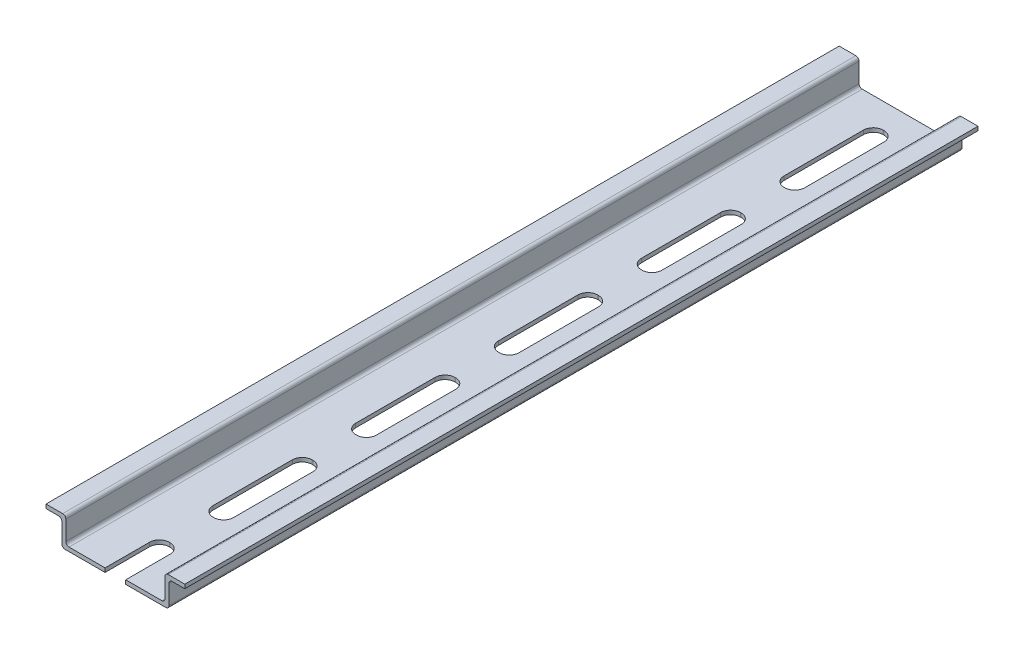
from build123d import *

# Parameters (mm, degrees)
BOSS_EXTRUDE1_DEPTH = 200
CUT_EXTRUDE1_DEPTH  = 2


with BuildPart() as part:
    # Sketch1 → Boss-Extrude1 (new body)
    with BuildSketch(Plane.XY):
        with BuildLine():
            Line((0, 0), (0, 1))
            Line((0, 1), (4.2, 1))
            ThreePointArc((4.2, 1), (4.765685425, 0.765685425), (5, 0.2))
            Line((5, 0.2), (5, -4.7))
            ThreePointArc((5, -4.7), (5.234314575, -5.265685425), (5.8, -5.5))
            Line((5.8, -5.5), (29.2, -5.5))
            ThreePointArc((29.2, -5.5), (29.765685425, -5.265685425), (30, -4.7))
            Line((30, -4.7), (30, 0.2))
            ThreePointArc((30, 0.2), (30.234314575, 0.765685425), (30.8, 1))
            Line((30.8, 1), (35, 1))
            Line((35, 1), (35, 0))
            Line((35, 0), (31.8, 0))
            ThreePointArc((31.8, 0), (31.234314575, -0.234314575), (31, -0.8))
            Line((31, -0.8), (31, -5.7))
            ThreePointArc((31, -5.7), (30.765685425, -6.265685425), (30.2, -6.5))
            Line((30.2, -6.5), (4.8, -6.5))
            ThreePointArc((4.8, -6.5), (4.234314575, -6.265685425), (4, -5.7))
            Line((4, -5.7), (4, -0.8))
            ThreePointArc((4, -0.8), (3.765685425, -0.234314575), (3.2, 0))
            Line((3.2, 0), (0, 0))
        make_face()
    extrude(amount=BOSS_EXTRUDE1_DEPTH)

    # Sketch2 → Cut-Extrude1 (cut, through all)
    with BuildSketch(Plane(origin=(0, -5.5, 0), x_dir=(1, 0, 0), z_dir=(0, 1, 0))):
        with BuildLine():
            Line((17.4, -6.300946702), (17.6, -6.300946702))
            ThreePointArc((17.6, -6.300946702), (19.367766953, -7.033179749), (20.1, -8.800946702))
            Line((20.1, -8.800946702), (20.1, -28.800946702))
            ThreePointArc((20.1, -28.800946702), (19.367766953, -30.568713655), (17.6, -31.300946702))
            Line((17.6, -31.300946702), (17.4, -31.300946702))
            ThreePointArc((17.4, -31.300946702), (15.632233047, -30.568713655), (14.9, -28.800946702))
            Line((14.9, -28.800946702), (14.9, -8.800946702))
            ThreePointArc((14.9, -8.800946702), (15.632233047, -7.033179749), (17.4, -6.300946702))
        make_face()
        with BuildLine():
            Line((14.9, -44.800946702), (14.9, -64.800946702))
            ThreePointArc((14.9, -64.800946702), (15.632233047, -66.568713655), (17.4, -67.300946702))
            Line((17.4, -67.300946702), (17.6, -67.300946702))
            ThreePointArc((17.6, -67.300946702), (19.367766953, -66.568713655), (20.1, -64.800946702))
            Line((20.1, -64.800946702), (20.1, -44.800946702))
            ThreePointArc((20.1, -44.800946702), (19.367766953, -43.033179749), (17.6, -42.300946702))
            Line((17.6, -42.300946702), (17.4, -42.300946702))
            ThreePointArc((17.4, -42.300946702), (15.632233047, -43.033179749), (14.9, -44.800946702))
        make_face()
        with BuildLine():
            Line((14.9, -80.800946702), (14.9, -100.800946702))
            ThreePointArc((14.9, -100.800946702), (15.632233047, -102.568713655), (17.4, -103.300946702))
            Line((17.4, -103.300946702), (17.6, -103.300946702))
            ThreePointArc((17.6, -103.300946702), (19.367766953, -102.568713655), (20.1, -100.800946702))
            Line((20.1, -100.800946702), (20.1, -80.800946702))
            ThreePointArc((20.1, -80.800946702), (19.367766953, -79.033179749), (17.6, -78.300946702))
            Line((17.6, -78.300946702), (17.4, -78.300946702))
            ThreePointArc((17.4, -78.300946702), (15.632233047, -79.033179749), (14.9, -80.800946702))
        make_face()
        with BuildLine():
            Line((14.9, -116.800946702), (14.9, -136.800946702))
            ThreePointArc((14.9, -136.800946702), (15.632233047, -138.568713655), (17.4, -139.300946702))
            Line((17.4, -139.300946702), (17.6, -139.300946702))
            ThreePointArc((17.6, -139.300946702), (19.367766953, -138.568713655), (20.1, -136.800946702))
            Line((20.1, -136.800946702), (20.1, -116.800946702))
            ThreePointArc((20.1, -116.800946702), (19.367766953, -115.033179749), (17.6, -114.300946702))
            Line((17.6, -114.300946702), (17.4, -114.300946702))
            ThreePointArc((17.4, -114.300946702), (15.632233047, -115.033179749), (14.9, -116.800946702))
        make_face()
        with BuildLine():
            Line((14.9, -152.800946702), (14.9, -172.800946702))
            ThreePointArc((14.9, -172.800946702), (15.632233047, -174.568713655), (17.4, -175.300946702))
            Line((17.4, -175.300946702), (17.6, -175.300946702))
            ThreePointArc((17.6, -175.300946702), (19.367766953, -174.568713655), (20.1, -172.800946702))
            Line((20.1, -172.800946702), (20.1, -152.800946702))
            ThreePointArc((20.1, -152.800946702), (19.367766953, -151.033179749), (17.6, -150.300946702))
            Line((17.6, -150.300946702), (17.4, -150.300946702))
            ThreePointArc((17.4, -150.300946702), (15.632233047, -151.033179749), (14.9, -152.800946702))
        make_face()
        with BuildLine():
            Line((14.9, -188.800946702), (14.9, -208.800946702))
            ThreePointArc((14.9, -208.800946702), (15.632233047, -210.568713655), (17.4, -211.300946702))
            Line((17.4, -211.300946702), (17.6, -211.300946702))
            ThreePointArc((17.6, -211.300946702), (19.367766953, -210.568713655), (20.1, -208.800946702))
            Line((20.1, -208.800946702), (20.1, -188.800946702))
            ThreePointArc((20.1, -188.800946702), (19.367766953, -187.033179749), (17.6, -186.300946702))
            Line((17.6, -186.300946702), (17.4, -186.300946702))
            ThreePointArc((17.4, -186.300946702), (15.632233047, -187.033179749), (14.9, -188.800946702))
        make_face()
    extrude(amount=-CUT_EXTRUDE1_DEPTH, mode=Mode.SUBTRACT)


solid = part.part
